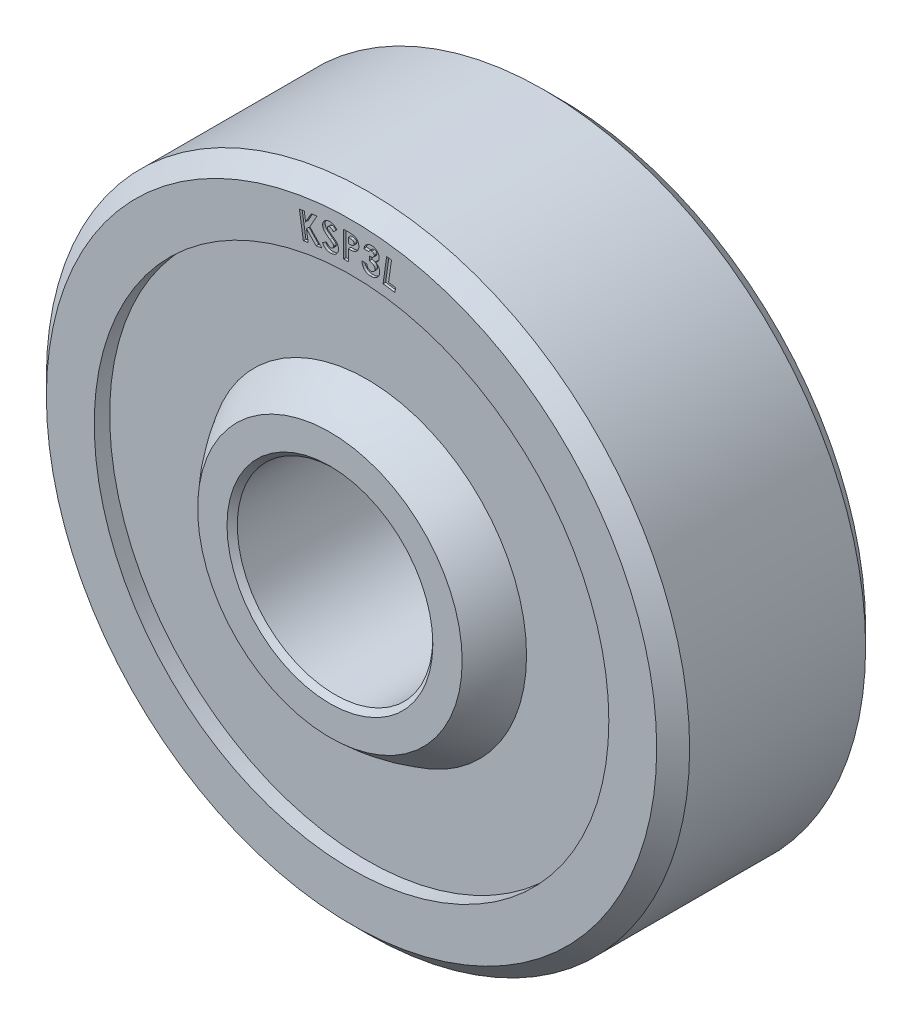
from build123d import *

# Parameters (mm, degrees)
CUT_EXTRUDE1_DEPTH = 0.0635


with BuildPart() as part:
    # Sketch1 → Revolve1 (revolve)
    with BuildSketch(Plane(origin=(0, 0, 0), x_dir=(0, 0, -1), z_dir=(1, 0, 0))):
        with BuildLine():
            Line((-3.1115, 2.54), (-3.1115, 3.2639))
            ThreePointArc((-3.1115, 3.2639), (-2.675609237, 3.629819647), (-2.1971, 3.937921666))
            Line((-2.1971, 3.937921666), (-2.1971, 6.35))
            Line((-2.1971, 6.35), (-2.5781, 6.35))
            Line((-2.5781, 6.35), (-2.5781, 7.5311))
            Line((-2.5781, 7.5311), (-2.1717, 7.9375))
            Line((-2.1717, 7.9375), (2.1717, 7.9375))
            Line((2.1717, 7.9375), (2.5781, 7.5311))
            Line((2.5781, 7.5311), (2.5781, 6.35))
            Line((2.5781, 6.35), (2.1971, 6.35))
            Line((2.1971, 6.35), (2.1971, 3.937921666))
            ThreePointArc((2.1971, 3.937921666), (2.675609237, 3.629819647), (3.1115, 3.2639))
            Line((3.1115, 3.2639), (3.1115, 2.54))
            Line((3.1115, 2.54), (2.9845, 2.413))
            Line((2.9845, 2.413), (-2.9845, 2.413))
            Line((-2.9845, 2.413), (-3.1115, 2.54))
        make_face()
    revolve(axis=Axis((0, 0, 0), (0, 0, -1)))

    # Sketch2 → Cut-Extrude1 (cut)
    with BuildSketch(Plane.XY.offset(2.5781)):
        Polygon((-1.286864037, 7.119168546), (-1.166402298, 7.137867465), (-1.133074974, 6.922639099), (-0.996712795, 7.164071391), (-0.853354421, 7.186332008), (-1.028768083, 6.873411335), (-0.735182346, 6.563925157), (-0.876378259, 6.542046151), (-1.112468003, 6.789838619), (-1.069473211, 6.512153322), (-1.18993495, 6.493454404), align=None)
        with BuildLine():
            Line((-0.362396166, 7.140986722), (-0.445078457, 7.055505953))
            add(Edge.make_bspline(
                [(-0.445078457, 7.055505953), (-0.449340655, 7.060354983), (-0.457503566, 7.069641788), (-0.470264495, 7.082112732), (-0.482993726, 7.092463396), (-0.495638489, 7.100888792), (-0.508257651, 7.10714885), (-0.520750252, 7.111526234), (-0.533242448, 7.113637199), (-0.541492941, 7.113467433), (-0.545569243, 7.113383557)],
                knots=[0, 0, 0, 0, 1.9364e-05, 3.7085e-05, 5.3455e-05, 6.852e-05, 8.2571e-05, 9.5604e-05, 0.00010811, 0.000120322, 0.000120322, 0.000120322, 0.000120322], degree=3))
            add(Edge.make_bspline(
                [(-0.545569243, 7.113383557), (-0.549328384, 7.11296736), (-0.556548887, 7.112167935), (-0.566645723, 7.10881735), (-0.575765306, 7.10434045), (-0.583250479, 7.098029499), (-0.589367465, 7.091155794), (-0.593788406, 7.083777762), (-0.596042836, 7.075949333), (-0.596060368, 7.070697577), (-0.596069042, 7.068099102)],
                knots=[0, 0, 0, 0, 1.1315e-05, 2.1734e-05, 3.1747e-05, 4.1601e-05, 5.0887e-05, 5.9265e-05, 6.7198e-05, 7.4967e-05, 7.4967e-05, 7.4967e-05, 7.4967e-05], degree=3))
            add(Edge.make_bspline(
                [(-0.596069042, 7.068099102), (-0.595744032, 7.065490294), (-0.595089745, 7.060238424), (-0.592276116, 7.052696417), (-0.588299473, 7.045435581), (-0.584778322, 7.04108182), (-0.582967079, 7.038842291)],
                knots=[0, 0, 0, 0, 7.863e-06, 1.5829e-05, 2.3971e-05, 3.2596e-05, 3.2596e-05, 3.2596e-05, 3.2596e-05], degree=3))
            add(Edge.make_bspline(
                [(-0.582967079, 7.038842291), (-0.58133817, 7.037120543), (-0.577561481, 7.033128603), (-0.570434606, 7.027022644), (-0.561588976, 7.019490939), (-0.550700292, 7.010886752), (-0.538022894, 7.000951529), (-0.523320379, 6.989880998), (-0.506711151, 6.977567104), (-0.494909424, 6.969036875), (-0.488709267, 6.964555432)],
                knots=[0, 0, 0, 0, 7.106e-06, 1.6476e-05, 2.8122e-05, 4.1968e-05, 5.81e-05, 7.6443e-05, 9.7178e-05, 0.000120128, 0.000120128, 0.000120128, 0.000120128], degree=3))
            add(Edge.make_bspline(
                [(-0.488709267, 6.964555432), (-0.482888129, 6.960416974), (-0.471848196, 6.952568287), (-0.456342823, 6.941153626), (-0.44250971, 6.931177556), (-0.430449692, 6.922395428), (-0.420337614, 6.914633584), (-0.411946481, 6.908141811), (-0.405260703, 6.902969406), (-0.401523242, 6.8997777), (-0.399921206, 6.898409598)],
                knots=[0, 0, 0, 0, 2.1427e-05, 4.0636e-05, 5.776e-05, 7.2593e-05, 8.539e-05, 9.5999e-05, 0.000104423, 0.000110742, 0.000110742, 0.000110742, 0.000110742], degree=3))
            add(Edge.make_bspline(
                [(-0.399921206, 6.898409598), (-0.393731626, 6.892815511), (-0.38186469, 6.882090279), (-0.366145256, 6.865294472), (-0.353142689, 6.848656013), (-0.34262048, 6.832068724), (-0.334476629, 6.815044093), (-0.328186175, 6.797371592), (-0.323790466, 6.778722357), (-0.322481773, 6.765884951), (-0.321818241, 6.759376145)],
                knots=[0, 0, 0, 0, 2.5021e-05, 4.7972e-05, 6.8913e-05, 8.8289e-05, 0.000106779, 0.000125407, 0.000144476, 0.000164087, 0.000164087, 0.000164087, 0.000164087], degree=3))
            add(Edge.make_bspline(
                [(-0.321818241, 6.759376145), (-0.321473715, 6.753016444), (-0.320797983, 6.740542912), (-0.322059709, 6.722097906), (-0.32477374, 6.704353255), (-0.329380571, 6.687328615), (-0.33579915, 6.671042087), (-0.34398012, 6.655498531), (-0.353864714, 6.640621621), (-0.365379015, 6.626610316), (-0.378295069, 6.613659295), (-0.392506209, 6.602102698), (-0.407947873, 6.59220191), (-0.42449429, 6.583766488), (-0.442108847, 6.57673139), (-0.460900537, 6.571297664), (-0.480815883, 6.567290735), (-0.494544094, 6.565948972), (-0.501556823, 6.565263565)],
                knots=[0, 0, 0, 0, 1.9091e-05, 3.7444e-05, 5.5346e-05, 7.2872e-05, 9.0234e-05, 0.000107759, 0.000125469, 0.000143727, 0.000162076, 0.000180254, 0.000198567, 0.000216999, 0.000235896, 0.000255378, 0.00027561, 0.000296737, 0.000296737, 0.000296737, 0.000296737], degree=3))
            add(Edge.make_bspline(
                [(-0.501556823, 6.565263565), (-0.507109267, 6.564925517), (-0.518040478, 6.564259996), (-0.534236642, 6.564713867), (-0.549955908, 6.566102675), (-0.565239147, 6.568463912), (-0.580019097, 6.572074652), (-0.594372486, 6.576642257), (-0.608217967, 6.582392718), (-0.621670616, 6.589166402), (-0.634710712, 6.597084537), (-0.647342165, 6.606281294), (-0.659531516, 6.616803563), (-0.671508508, 6.62832118), (-0.682994745, 6.641177275), (-0.694176878, 6.65520877), (-0.705140745, 6.670392679), (-0.711847234, 6.681230076), (-0.715258746, 6.686742932)],
                knots=[0, 0, 0, 0, 1.6681e-05, 3.284e-05, 4.8549e-05, 6.4004e-05, 7.9183e-05, 9.4148e-05, 0.000109148, 0.000124109, 0.000139293, 0.000154864, 0.000170924, 0.000187567, 0.00020468, 0.000222599, 0.000241379, 0.000260823, 0.000260823, 0.000260823, 0.000260823], degree=3))
            Line((-0.715258746, 6.686742932), (-0.618965677, 6.755432836))
            add(Edge.make_bspline(
                [(-0.618965677, 6.755432836), (-0.614699558, 6.749126182), (-0.606516916, 6.737029688), (-0.59318714, 6.72085651), (-0.579618559, 6.707255746), (-0.565754601, 6.696374201), (-0.551638282, 6.68799408), (-0.537226272, 6.682513035), (-0.522561972, 6.679252035), (-0.512723599, 6.67958151), (-0.507789796, 6.679746738)],
                knots=[0, 0, 0, 0, 2.2832e-05, 4.3793e-05, 6.2772e-05, 8.0355e-05, 9.6543e-05, 0.000111804, 0.000126473, 0.000141229, 0.000141229, 0.000141229, 0.000141229], degree=3))
            add(Edge.make_bspline(
                [(-0.507789796, 6.679746738), (-0.502835692, 6.680335049), (-0.493210604, 6.681478051), (-0.47969931, 6.686054447), (-0.467518551, 6.692632027), (-0.457169909, 6.701372099), (-0.44864186, 6.711257611), (-0.442568175, 6.721982686), (-0.43928821, 6.733404447), (-0.439416882, 6.741124894), (-0.439481502, 6.745002147)],
                knots=[0, 0, 0, 0, 1.4932e-05, 2.9011e-05, 4.2503e-05, 5.6233e-05, 6.9409e-05, 8.148e-05, 9.296e-05, 0.000104542, 0.000104542, 0.000104542, 0.000104542], degree=3))
            add(Edge.make_bspline(
                [(-0.439481502, 6.745002147), (-0.439940651, 6.748593583), (-0.440875643, 6.755907052), (-0.444884271, 6.766580329), (-0.450884059, 6.776957787), (-0.45737105, 6.785440311), (-0.463909258, 6.792442705), (-0.470179262, 6.798398121), (-0.477697638, 6.805007712), (-0.486490838, 6.812191784), (-0.496392033, 6.820178166), (-0.507800128, 6.828434345), (-0.520179013, 6.83768675), (-0.529013049, 6.843824183), (-0.533612111, 6.847019374)],
                knots=[0, 0, 0, 0, 1.0832e-05, 2.2059e-05, 3.3908e-05, 4.6705e-05, 5.3996e-05, 6.2632e-05, 7.2636e-05, 8.4021e-05, 9.6695e-05, 0.00011079, 0.000126258, 0.000143057, 0.000143057, 0.000143057, 0.000143057], degree=3))
            add(Edge.make_bspline(
                [(-0.533612111, 6.847019374), (-0.542365517, 6.853183573), (-0.559155495, 6.865007172), (-0.583038988, 6.882455357), (-0.604512969, 6.898938934), (-0.623590096, 6.914435348), (-0.64032436, 6.928834225), (-0.654791533, 6.942119445), (-0.666748812, 6.954546179), (-0.679382043, 6.969435289), (-0.691768531, 6.98773314), (-0.703166058, 7.009978797), (-0.71088297, 7.03262718), (-0.712876348, 7.048034212), (-0.713859507, 7.055633156)],
                knots=[0, 0, 0, 0, 3.2118e-05, 6.1605e-05, 8.8727e-05, 0.000113322, 0.000135329, 0.00015495, 0.000172224, 0.000187028, 0.00021349, 0.000238293, 0.000261865, 0.000284805, 0.000284805, 0.000284805, 0.000284805], degree=3))
            add(Edge.make_bspline(
                [(-0.713859507, 7.055633156), (-0.7141465, 7.061017572), (-0.714714304, 7.071670429), (-0.713510204, 7.087502462), (-0.710692122, 7.102839122), (-0.706348068, 7.117735688), (-0.700347719, 7.132161429), (-0.692642905, 7.146061634), (-0.683391406, 7.159511692), (-0.672704311, 7.172375281), (-0.660647313, 7.184197503), (-0.647835722, 7.195014421), (-0.633992737, 7.204154982), (-0.619407773, 7.211999551), (-0.603928149, 7.218361376), (-0.587625518, 7.223337827), (-0.570442089, 7.226774847), (-0.558684047, 7.228003752), (-0.55269264, 7.228629951)],
                knots=[0, 0, 0, 0, 1.6163e-05, 3.1978e-05, 4.7496e-05, 6.2873e-05, 7.8441e-05, 9.4268e-05, 0.000110462, 0.000127352, 0.000144352, 0.000161062, 0.000177573, 0.00019402, 0.000210674, 0.000227695, 0.000245083, 0.000263148, 0.000263148, 0.000263148, 0.000263148], degree=3))
            add(Edge.make_bspline(
                [(-0.55269264, 7.228629951), (-0.544886908, 7.22901211), (-0.529320163, 7.229774239), (-0.506085683, 7.227118546), (-0.483173319, 7.222073884), (-0.464482167, 7.215309712), (-0.44952725, 7.208416011), (-0.43786435, 7.202189241), (-0.426089306, 7.194568872), (-0.413884343, 7.186078629), (-0.401330082, 7.176482822), (-0.38858676, 7.16566206), (-0.375418274, 7.153845035), (-0.366813447, 7.145348441), (-0.362396166, 7.140986722)],
                knots=[0, 0, 0, 0, 2.3411e-05, 4.6688e-05, 6.9895e-05, 9.3674e-05, 0.000106138, 0.000119285, 0.000133295, 0.000148186, 0.000163884, 0.000180676, 0.000198328, 0.000216949, 0.000216949, 0.000216949, 0.000216949], degree=3))
        make_face()
        with BuildLine():
            Line((-0.194045331, 7.233587646), (-0.066841806, 7.233587646))
            add(Edge.make_bspline(
                [(-0.066841806, 7.233587646), (-0.058530492, 7.233550443), (-0.042496227, 7.23347867), (-0.019373496, 7.23260833), (0.001958354, 7.231048627), (0.021494425, 7.22912108), (0.039226682, 7.226418735), (0.055177332, 7.223320708), (0.069349685, 7.219546409), (0.081903556, 7.215066369), (0.09317025, 7.209784576), (0.103832175, 7.20415909), (0.113648373, 7.197445271), (0.123114295, 7.190366706), (0.13168876, 7.182247182), (0.139906692, 7.173627065), (0.14742004, 7.164164488), (0.154263619, 7.153973994), (0.1604718, 7.14324386), (0.165895682, 7.131954902), (0.170295231, 7.120089258), (0.173985906, 7.107723684), (0.176950292, 7.094858719), (0.178923481, 7.081415244), (0.180263771, 7.067487124), (0.180382033, 7.058007637), (0.180441848, 7.053213047)],
                knots=[0, 0, 0, 0, 2.4933e-05, 4.8101e-05, 6.9399e-05, 8.9094e-05, 0.000106976, 0.000123191, 0.000137817, 0.000150935, 0.000163115, 0.000175125, 0.00018705, 0.000198753, 0.000210544, 0.000222423, 0.000234462, 0.000246739, 0.000259219, 0.000271623, 0.000284263, 0.000297141, 0.000310318, 0.000323828, 0.000337878, 0.000352257, 0.000352257, 0.000352257, 0.000352257], degree=3))
            add(Edge.make_bspline(
                [(0.180441848, 7.053213047), (0.180355303, 7.047908906), (0.180185231, 7.037485616), (0.178517978, 7.022206353), (0.175669782, 7.007638958), (0.171947339, 6.993660584), (0.166756657, 6.980501204), (0.160826547, 6.967846832), (0.15353063, 6.956052259), (0.145193879, 6.944969947), (0.136089196, 6.934509792), (0.126000435, 6.924973812), (0.115119894, 6.916297001), (0.103510555, 6.908388424), (0.091128835, 6.901264035), (0.077983666, 6.894857121), (0.063985286, 6.889372596), (0.054237235, 6.886504234), (0.049295013, 6.885049986)],
                knots=[0, 0, 0, 0, 1.5909e-05, 3.1262e-05, 4.6031e-05, 6.0412e-05, 7.4586e-05, 8.8411e-05, 0.000102286, 0.000116101, 0.000129982, 0.000143838, 0.000157684, 0.000171691, 0.000185939, 0.000200503, 0.000215526, 0.000230976, 0.000230976, 0.000230976, 0.000230976], degree=3))
            add(Edge.make_bspline(
                [(0.049295013, 6.885049986), (0.046039782, 6.884240079), (0.038987902, 6.88248556), (0.027318978, 6.880704283), (0.013871768, 6.879066508), (-0.001397211, 6.877659039), (-0.018496762, 6.876702288), (-0.037410329, 6.875955107), (-0.058146482, 6.87541183), (-0.072565584, 6.875392552), (-0.080070972, 6.875382518)],
                knots=[0, 0, 0, 0, 1.0059e-05, 2.179e-05, 3.5375e-05, 5.0703e-05, 6.7779e-05, 8.6748e-05, 0.000107488, 0.000130004, 0.000130004, 0.000130004, 0.000130004], degree=3))
            Line((-0.080070972, 6.875382518), (-0.080070972, 6.598587646))
            Line((-0.080070972, 6.598587646), (-0.194045331, 6.598587646))
            Line((-0.194045331, 6.598587646), (-0.194045331, 7.233587646))
        make_face()
        with BuildLine():
            Line((-0.080070972, 6.989356877), (-0.039747455, 6.989356877))
            add(Edge.make_bspline(
                [(-0.039747455, 6.989356877), (-0.032409954, 6.989403402), (-0.018908844, 6.98948901), (-0.000471095, 6.990726944), (0.014345835, 6.99261752), (0.026051484, 6.995329044), (0.035294203, 6.999444139), (0.04326547, 7.00420453), (0.050102629, 7.010223913), (0.056022602, 7.017102088), (0.060755442, 7.025005456), (0.06403742, 7.033805326), (0.066169329, 7.043316803), (0.06636623, 7.049936162), (0.066467489, 7.05334025)],
                knots=[0, 0, 0, 0, 2.201e-05, 4.0498e-05, 5.5393e-05, 6.6808e-05, 7.6379e-05, 8.5629e-05, 9.4556e-05, 0.000103579, 0.000112764, 0.000122024, 0.000131655, 0.000141851, 0.000141851, 0.000141851, 0.000141851], degree=3))
            add(Edge.make_bspline(
                [(0.066467489, 7.05334025), (0.066367272, 7.056314358), (0.066172826, 7.062084843), (0.064744372, 7.070413084), (0.062467827, 7.078176722), (0.059169201, 7.085294677), (0.05490486, 7.091754855), (0.049705764, 7.097554709), (0.043638629, 7.10281845), (0.038954446, 7.105604629), (0.036574661, 7.107020138)],
                knots=[0, 0, 0, 0, 8.919e-06, 1.7305e-05, 2.5273e-05, 3.3127e-05, 4.0747e-05, 4.8406e-05, 5.6436e-05, 6.4728e-05, 6.4728e-05, 6.4728e-05, 6.4728e-05], degree=3))
            add(Edge.make_bspline(
                [(0.036574661, 7.107020138), (0.034558845, 7.108039594), (0.030290951, 7.11019799), (0.023022313, 7.112707284), (0.014634416, 7.11482415), (0.005070633, 7.116581128), (-0.005630886, 7.117944725), (-0.017468229, 7.118987536), (-0.030458817, 7.119406891), (-0.039492993, 7.119542591), (-0.044199578, 7.119613287)],
                knots=[0, 0, 0, 0, 6.771e-06, 1.4335e-05, 2.3004e-05, 3.2709e-05, 4.3485e-05, 5.5359e-05, 6.8344e-05, 8.2466e-05, 8.2466e-05, 8.2466e-05, 8.2466e-05], degree=3))
            Line((-0.044199578, 7.119613287), (-0.080070972, 7.119613287))
            Line((-0.080070972, 7.119613287), (-0.080070972, 6.989356877))
        make_face(mode=Mode.SUBTRACT)
        with BuildLine():
            Line((0.421046942, 7.064120652), (0.30554614, 7.072388881))
            add(Edge.make_bspline(
                [(0.30554614, 7.072388881), (0.306769414, 7.078051934), (0.309165601, 7.089144895), (0.314242435, 7.105087813), (0.320024017, 7.12019014), (0.32694604, 7.134251334), (0.334545038, 7.147556988), (0.343414895, 7.159714064), (0.35300397, 7.171143343), (0.36021583, 7.177908106), (0.363805355, 7.181275099)],
                knots=[0, 0, 0, 0, 1.7372e-05, 3.4028e-05, 5.0138e-05, 6.584e-05, 8.1003e-05, 9.6041e-05, 0.000110928, 0.000125681, 0.000125681, 0.000125681, 0.000125681], degree=3))
            add(Edge.make_bspline(
                [(0.363805355, 7.181275099), (0.369016287, 7.185675015), (0.379263621, 7.194327482), (0.396054764, 7.205177658), (0.413525087, 7.214299286), (0.431866589, 7.221424721), (0.451022727, 7.226563391), (0.470934507, 7.22964308), (0.491631193, 7.231203629), (0.505636971, 7.230486171), (0.512760684, 7.230121253)],
                knots=[0, 0, 0, 0, 2.0442e-05, 4.02e-05, 5.9828e-05, 7.9482e-05, 9.9106e-05, 0.000119203, 0.000139857, 0.000161237, 0.000161237, 0.000161237, 0.000161237], degree=3))
            add(Edge.make_bspline(
                [(0.512760684, 7.230121253), (0.519090722, 7.22950042), (0.531529941, 7.228280416), (0.549714367, 7.224763422), (0.566910411, 7.219385677), (0.583418662, 7.21310238), (0.598757868, 7.2047348), (0.613355439, 7.195230371), (0.62702174, 7.184082829), (0.639585326, 7.171568769), (0.650987039, 7.158193954), (0.660873967, 7.144188355), (0.668895744, 7.129607114), (0.675313582, 7.114658429), (0.680084836, 7.09922988), (0.683131467, 7.083324082), (0.684446897, 7.066934938), (0.683965416, 7.055937459), (0.683722222, 7.050382671)],
                knots=[0, 0, 0, 0, 1.9076e-05, 3.7487e-05, 5.5434e-05, 7.3079e-05, 9.0379e-05, 0.000107737, 0.000125279, 0.000143178, 0.000160867, 0.000177946, 0.000194515, 0.0002107, 0.000226673, 0.000242864, 0.000259196, 0.000275864, 0.000275864, 0.000275864, 0.000275864], degree=3))
            add(Edge.make_bspline(
                [(0.683722222, 7.050382671), (0.682958568, 7.043516588), (0.681450575, 7.029958074), (0.675497729, 7.010384869), (0.666975473, 6.991915153), (0.655499119, 6.974771822), (0.641505425, 6.959080198), (0.624829736, 6.945250533), (0.605786114, 6.933153545), (0.591720456, 6.926981826), (0.584503472, 6.923815163)],
                knots=[0, 0, 0, 0, 2.0688e-05, 4.0852e-05, 6.1055e-05, 8.1517e-05, 0.000102508, 0.000123908, 0.000146318, 0.000169933, 0.000169933, 0.000169933, 0.000169933], degree=3))
            add(Edge.make_bspline(
                [(0.584503472, 6.923815163), (0.589070445, 6.921974462), (0.598089049, 6.918339547), (0.610893244, 6.911805517), (0.622932986, 6.904705809), (0.634093799, 6.896761419), (0.64435975, 6.888000081), (0.653794036, 6.878515679), (0.662574026, 6.868463003), (0.670218487, 6.85750793), (0.677135822, 6.846131948), (0.682886936, 6.834190471), (0.687562706, 6.821878171), (0.691297827, 6.809169674), (0.693992417, 6.79606947), (0.695459686, 6.782529864), (0.69602036, 6.768623989), (0.695540782, 6.759255181), (0.695297743, 6.754507271)],
                knots=[0, 0, 0, 0, 1.4765e-05, 2.9158e-05, 4.3076e-05, 5.6666e-05, 7.0201e-05, 8.3513e-05, 9.6772e-05, 0.000110184, 0.000123535, 0.000136677, 0.000149883, 0.000163005, 0.000176377, 0.000189946, 0.000203821, 0.000218077, 0.000218077, 0.000218077, 0.000218077], degree=3))
            add(Edge.make_bspline(
                [(0.695297743, 6.754507271), (0.694632224, 6.747576341), (0.693319198, 6.733902068), (0.688938563, 6.713928805), (0.682532658, 6.694951051), (0.674394064, 6.67687081), (0.664226299, 6.659846063), (0.652201285, 6.643699581), (0.63814786, 6.628594889), (0.622426814, 6.614561066), (0.605414443, 6.601822049), (0.587070051, 6.591175033), (0.567970824, 6.58215264), (0.547819229, 6.575285078), (0.526770679, 6.570325798), (0.504755987, 6.567304716), (0.481809226, 6.566103975), (0.466245176, 6.566872321), (0.458317575, 6.567263681)],
                knots=[0, 0, 0, 0, 2.0875e-05, 4.1184e-05, 6.1176e-05, 8.0873e-05, 0.000100551, 0.000120547, 0.000141161, 0.00016233, 0.000183701, 0.000204797, 0.000225853, 0.000246972, 0.000268539, 0.00029063, 0.000313555, 0.000337355, 0.000337355, 0.000337355, 0.000337355], degree=3))
            add(Edge.make_bspline(
                [(0.458317575, 6.567263681), (0.450839814, 6.567994624), (0.436225246, 6.569423183), (0.41491988, 6.573510175), (0.394879972, 6.579350279), (0.375932788, 6.586764044), (0.358228509, 6.595914785), (0.341755406, 6.606830921), (0.326336359, 6.619222493), (0.312281494, 6.633311875), (0.299695086, 6.648847576), (0.288684245, 6.665563512), (0.279479548, 6.683477466), (0.272138327, 6.70252295), (0.266366141, 6.7226545), (0.262343308, 6.74389618), (0.259983607, 6.766324998), (0.259915162, 6.781638195), (0.259880075, 6.78948824)],
                knots=[0, 0, 0, 0, 2.2532e-05, 4.4036e-05, 6.4969e-05, 8.5071e-05, 0.000104983, 0.000124635, 0.000144262, 0.00016423, 0.000184216, 0.00020415, 0.000224175, 0.000244514, 0.000265289, 0.000286918, 0.000309296, 0.000332835, 0.000332835, 0.000332835, 0.000332835], degree=3))
            Line((0.259880075, 6.78948824), (0.378815371, 6.780965604))
            add(Edge.make_bspline(
                [(0.378815371, 6.780965604), (0.379227759, 6.77697236), (0.380034171, 6.769163702), (0.382110754, 6.757919604), (0.384591889, 6.747337832), (0.38791841, 6.73756428), (0.391839641, 6.728479047), (0.396476443, 6.720155062), (0.401619755, 6.712493635), (0.409498692, 6.703520586), (0.420668342, 6.693853138), (0.436282144, 6.685248422), (0.453786659, 6.679348921), (0.466243026, 6.67791161), (0.472691573, 6.677167527)],
                knots=[0, 0, 0, 0, 1.2039e-05, 2.3541e-05, 3.4278e-05, 4.4616e-05, 5.4471e-05, 6.3922e-05, 7.3166e-05, 8.2093e-05, 9.9684e-05, 0.000117167, 0.000135268, 0.000154698, 0.000154698, 0.000154698, 0.000154698], degree=3))
            add(Edge.make_bspline(
                [(0.472691573, 6.677167527), (0.476124832, 6.677034786), (0.482867529, 6.67677409), (0.49284975, 6.677208443), (0.502444821, 6.678845046), (0.511687629, 6.681014485), (0.520489763, 6.68429562), (0.528855457, 6.688380576), (0.536985551, 6.693206387), (0.544501606, 6.699056912), (0.551460776, 6.705467338), (0.55762889, 6.71241865), (0.563034202, 6.719789167), (0.56740631, 6.727712204), (0.571214236, 6.735913063), (0.573996439, 6.744630588), (0.575899822, 6.753805), (0.576544576, 6.760096519), (0.57687126, 6.763284314)],
                knots=[0, 0, 0, 0, 1.0307e-05, 2.0242e-05, 2.9903e-05, 3.9467e-05, 4.8683e-05, 5.8013e-05, 6.7372e-05, 7.6989e-05, 8.653e-05, 9.5721e-05, 0.00010483, 0.000113886, 0.000122824, 0.000131915, 0.000141271, 0.000150879, 0.000150879, 0.000150879, 0.000150879], degree=3))
            add(Edge.make_bspline(
                [(0.57687126, 6.763284314), (0.576998181, 6.766805445), (0.577248036, 6.773737117), (0.576157269, 6.784023508), (0.57404705, 6.79399789), (0.57054863, 6.80365469), (0.565783789, 6.812893819), (0.560056849, 6.821928199), (0.552928069, 6.830469726), (0.544730595, 6.838718294), (0.535291687, 6.846327155), (0.524780278, 6.853245338), (0.5131917, 6.859330028), (0.500506631, 6.864575334), (0.48668989, 6.86884191), (0.471825079, 6.872406038), (0.455836795, 6.875064535), (0.44479921, 6.876176627), (0.439109842, 6.876749859)],
                knots=[0, 0, 0, 0, 1.0559e-05, 2.0786e-05, 3.094e-05, 4.108e-05, 5.1491e-05, 6.2076e-05, 7.3103e-05, 8.4796e-05, 9.6914e-05, 0.000109403, 0.00012249, 0.000136121, 0.000150523, 0.000165827, 0.00018195, 0.000199102, 0.000199102, 0.000199102, 0.000199102], degree=3))
            Line((0.439109842, 6.876749859), (0.446487647, 6.979784715))
            add(Edge.make_bspline(
                [(0.446487647, 6.979784715), (0.45331655, 6.979968732), (0.466062837, 6.980312204), (0.483863025, 6.981822121), (0.498926646, 6.984603781), (0.511685118, 6.98820944), (0.522406405, 6.993278231), (0.531846089, 6.999067417), (0.540178799, 7.005939569), (0.547254954, 7.013806733), (0.553080154, 7.022373131), (0.5574903, 7.03145133), (0.560525174, 7.040878233), (0.561247375, 7.047393984), (0.561606837, 7.050637078)],
                knots=[0, 0, 0, 0, 2.0494e-05, 3.8252e-05, 5.3521e-05, 6.6399e-05, 7.7896e-05, 8.8979e-05, 9.9549e-05, 0.000110177, 0.00012062, 0.000130519, 0.000140376, 0.000150144, 0.000150144, 0.000150144, 0.000150144], degree=3))
            add(Edge.make_bspline(
                [(0.561606837, 7.050637078), (0.561692432, 7.054761752), (0.561859363, 7.062805966), (0.559220524, 7.074549688), (0.554155874, 7.085297054), (0.546807834, 7.094840622), (0.537684781, 7.103035553), (0.526713959, 7.109243183), (0.514209413, 7.113360058), (0.505286411, 7.114358839), (0.500676349, 7.114874859)],
                knots=[0, 0, 0, 0, 1.2341e-05, 2.4069e-05, 3.5734e-05, 4.7717e-05, 5.9971e-05, 7.2278e-05, 8.527e-05, 9.9158e-05, 9.9158e-05, 9.9158e-05, 9.9158e-05], degree=3))
            add(Edge.make_bspline(
                [(0.500676349, 7.114874859), (0.496426913, 7.115037699), (0.488034552, 7.115359297), (0.475665769, 7.112994333), (0.463749899, 7.108913342), (0.452592703, 7.102766059), (0.442230246, 7.095275497), (0.433574238, 7.086071909), (0.426188498, 7.075781422), (0.422780382, 7.068052002), (0.421046942, 7.064120652)],
                knots=[0, 0, 0, 0, 1.272e-05, 2.5122e-05, 3.7512e-05, 5.0375e-05, 6.3197e-05, 7.5703e-05, 8.8125e-05, 0.000100982, 0.000100982, 0.000100982, 0.000100982], degree=3))
        make_face()
        Polygon((0.866523455, 7.181696791), (0.985585955, 7.164905926), (0.913715963, 6.652784532), (1.087221572, 6.628488658), (1.071193928, 6.51489591), (0.778625819, 6.555982649), align=None)
    extrude(amount=-CUT_EXTRUDE1_DEPTH, mode=Mode.SUBTRACT)


solid = part.part
